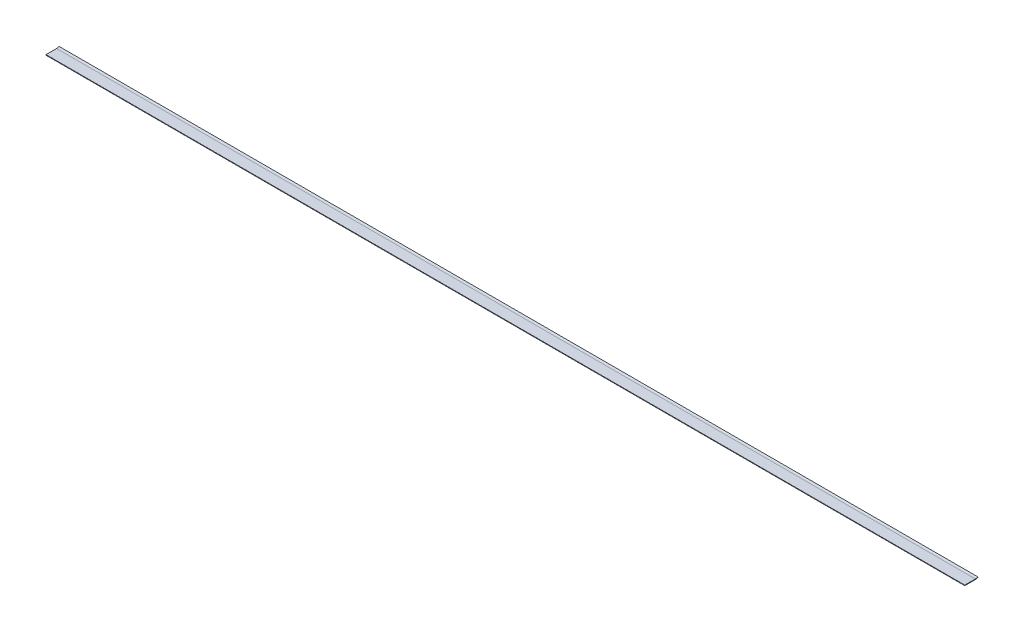
from build123d import *

# Parameters (mm, degrees)
EXTRUDE_THIN1_DEPTH = 217.4875


with BuildPart() as part:
    # Sketch1 → Extrude-Thin1 (new body)
    with BuildSketch(Plane(origin=(0, 0, 0), x_dir=(0, 0, -1), z_dir=(1, 0, 0))):
        with BuildLine():
            ThreePointArc((0.614869388, 0.207178861), (0.324417726, 0.053186862), (0, 0))
            Line((0, 0), (-2.5146, 0))
            Line((-2.5146, 0), (-2.5146, 0.127))
            Line((-2.5146, 0.127), (0, 0.127))
            ThreePointArc((0, 0.127), (0.283865511, 0.173538504), (0.538010715, 0.308281503))
            Line((0.538010715, 0.308281503), (0.614869388, 0.207178861))
        make_face()
    extrude(amount=-EXTRUDE_THIN1_DEPTH)


solid = part.part
